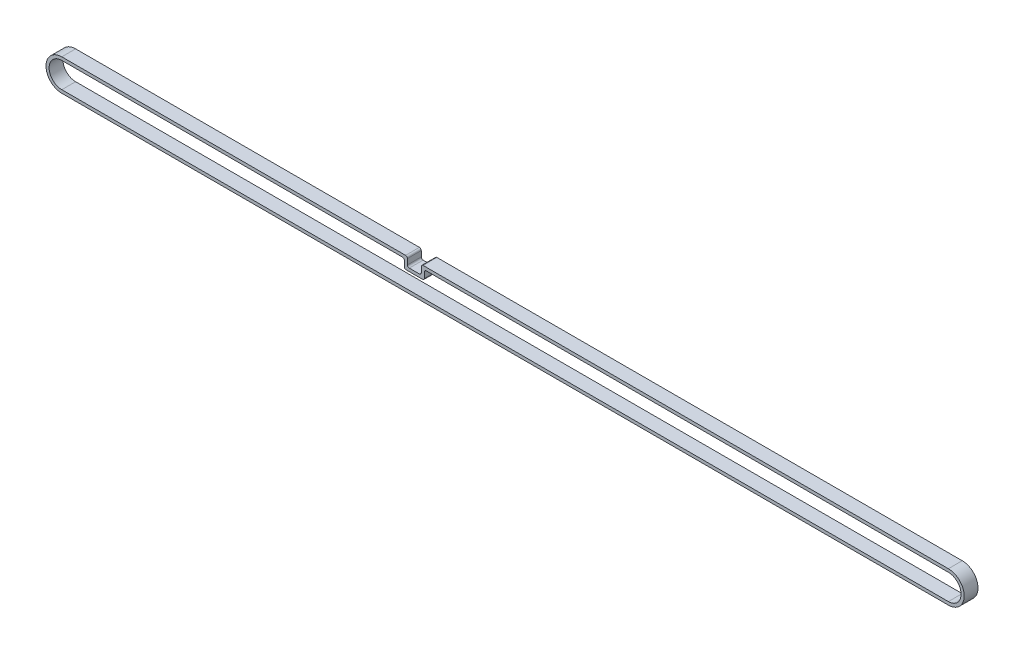
from build123d import *

# Parameters (mm, degrees)
SALIENTE_EXTRUIR1_DEPTH = 6
REDONDEO1_R             = 0.8


with BuildPart() as part:
    # Croquis1 → Saliente-Extruir1 (new body)
    with BuildSketch(Plane.XY):
        with BuildLine():
            Line((0, 6.85), (150, 6.85))
            Line((150, 6.85), (150, 2.85))
            Line((150, 2.85), (156, 2.85))
            Line((156, 2.85), (156, 6.85))
            Line((156, 6.85), (384.75, 6.85))
            ThreePointArc((384.75, 6.85), (391.6, 0), (384.75, -6.85))
            Line((384.75, -6.85), (0, -6.85))
            ThreePointArc((0, -6.85), (-6.85, 0), (0, 6.85))
        make_face()
        with BuildLine():
            Line((0, 5.5), (148.65, 5.5))
            Line((148.65, 5.5), (148.65, 1.5))
            Line((148.65, 1.5), (157.35, 1.5))
            Line((157.35, 1.5), (157.35, 5.5))
            Line((157.35, 5.5), (384.75, 5.5))
            ThreePointArc((384.75, 5.5), (390.25, 0), (384.75, -5.5))
            Line((384.75, -5.5), (0, -5.5))
            ThreePointArc((0, -5.5), (-5.5, 0), (0, 5.5))
        make_face(mode=Mode.SUBTRACT)
    extrude(amount=SALIENTE_EXTRUIR1_DEPTH)

    # Redondeo1
    redondeo1_edges = [part.edges().sort_by_distance(p)[0] for p in [
        (150, 6.85, 3),
        (150, 2.85, 3),
        (156, 2.85, 3),
        (156, 6.85, 3),
        (157.35, 5.5, 3),
        (157.35, 1.5, 3),
        (148.65, 1.5, 3),
        (148.65, 5.5, 3),
    ]]
    fillet(redondeo1_edges, radius=REDONDEO1_R)


solid = part.part
